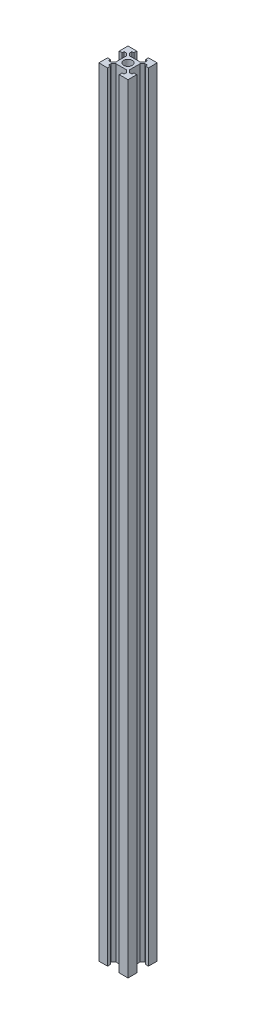
from build123d import *

# Parameters (mm, degrees)
SKETCH1_R           = 9
BOSS_EXTRUDE1_DEPTH = 1600


with BuildPart() as part:
    # Sketch1 → Boss-Extrude1 (new body)
    with BuildSketch(Plane(origin=(0, 0, 0), x_dir=(1, 0, 0), z_dir=(0, 1, 0))):
        Polygon((-30, 30), (-12, 30), (-12, 24), (-16, 24), (-16, 19), (-11, 14), (11, 14), (16, 19), (16, 24), (12, 24), (12, 30), (30, 30), (30, 12), (24, 12), (24, 16), (19, 16), (14, 11), (14, -11), (19, -16), (24, -16), (24, -12), (30, -12), (30, -30), (12, -30), (12, -24), (16, -24), (16, -19), (11, -14), (-11, -14), (-16, -19), (-16, -24), (-12, -24), (-12, -30), (-30, -30), (-30, -12), (-24, -12), (-24, -16), (-19, -16), (-14, -11), (-14, 11), (-19, 16), (-24, 16), (-24, 12), (-30, 12), align=None)
        Circle(SKETCH1_R, mode=Mode.SUBTRACT)
    extrude(amount=BOSS_EXTRUDE1_DEPTH)


solid = part.part
